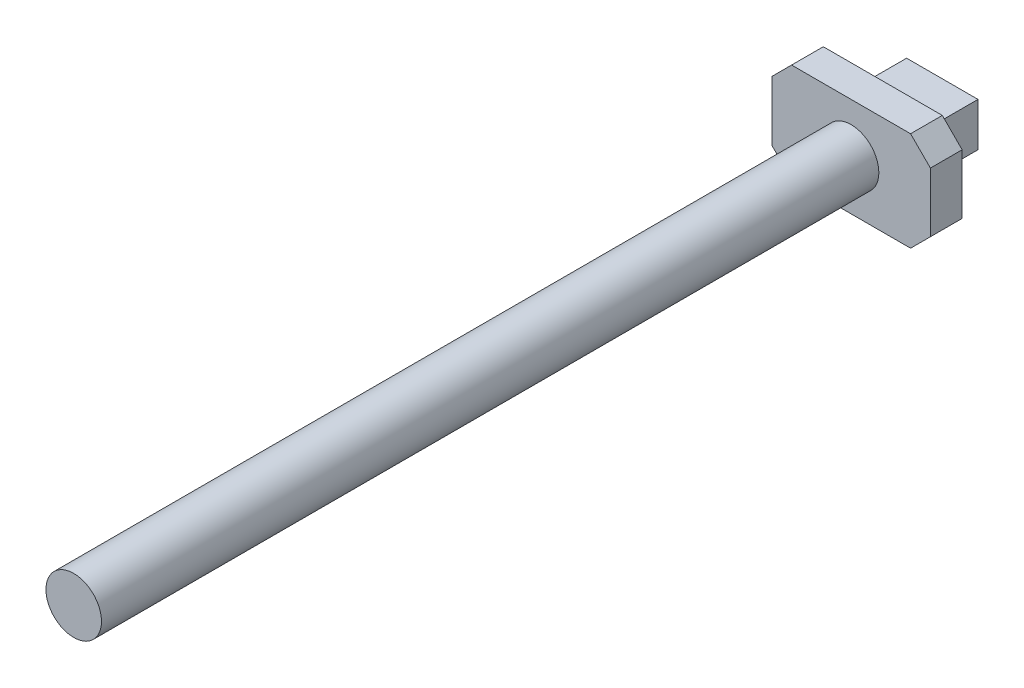
from build123d import *

# Parameters (mm, degrees)
SKETCH_1_R             = 7
EXTRUDE_1_DEPTH        = 160
EXTRUDE_1_DEPTH_BACK   = 36
SKETCH_2_R             = 7
EXTRUDE_2_DEPTH        = 8
SKETCH_3_W             = 18
SKETCH_3_H             = 11
EXTRUDE_3_DEPTH        = 15
EXTRUDE_4_DEPTH        = 30
SKETCH_5_W             = 60
SKETCH_5_H             = 40
EXTRUDE_5_DEPTH        = 6
SKETCH_6_W             = 60
SKETCH_6_H             = 6
EXTRUDE_6_DEPTH        = 60
SKETCH_7_W             = 29.455878384
SKETCH_7_H             = 4
EXTRUDE_7_DEPTH        = 8
PATTERN_LINEAR_1_COUNT = 2
PATTERN_LINEAR_1_PITCH = 52
SKETCH_8_W             = 118.40385017
SKETCH_8_H             = 95.184754192
CUT_EXTRUDE_1_DEPTH    = 200


with BuildPart() as part:
    # 草图1 → 凸台-拉伸1 (new body, two sides)
    with BuildSketch(Plane.XY) as extrude_1_sk:
        Circle(SKETCH_1_R)
    extrude(amount=EXTRUDE_1_DEPTH)
    extrude(extrude_1_sk.sketch, amount=-EXTRUDE_1_DEPTH_BACK)

    # 草图2 → 凸台-拉伸2 (add)
    with BuildSketch(Plane(origin=(0, 0, -36), x_dir=(-1, 0, 0), z_dir=(0, 0, -1))):
        Polygon((20, 7.5), (15, 12.5), (-15, 12.5), (-20, 7.5), (-20, -7.5), (-15, -12.5), (15, -12.5), (20, -7.5), align=None)
        Circle(SKETCH_2_R, mode=Mode.SUBTRACT)
        Circle(SKETCH_2_R)
    extrude(amount=EXTRUDE_2_DEPTH)

    # 草图3 → 凸台-拉伸3 (add)
    with BuildSketch(Plane(origin=(0, 0, -44), x_dir=(-1, 0, 0), z_dir=(0, 0, -1))):
        Rectangle(SKETCH_3_W, SKETCH_3_H)
    extrude(amount=EXTRUDE_3_DEPTH)

    # 草图4 → 凸台-拉伸4 (add)
    with BuildSketch(Plane(origin=(0, 0, -59), x_dir=(-1, 0, 0), z_dir=(0, 0, -1))):
        with BuildLine():
            Line((-15, -12.5), (-15, 12.5))
            ThreePointArc((-15, 12.5), (-27.5, 0), (-15, -12.5))
        make_face()
        with BuildLine():
            ThreePointArc((-3.77502784, 5.5), (-8.385621722, 10.606601718), (-15, 12.5))
            Line((-15, 12.5), (-15, -12.5))
            ThreePointArc((-15, -12.5), (-8.385621722, -10.606601718), (-3.77502784, -5.5))
            Line((-3.77502784, -5.5), (-9, -5.5))
            Line((-9, -5.5), (-9, 5.5))
            Line((-9, 5.5), (-3.77502784, 5.5))
        make_face()
        with BuildLine():
            ThreePointArc((-2.5, 0), (-2.822928267, 2.822928267), (-3.77502784, 5.5))
            Line((-3.77502784, 5.5), (-9, 5.5))
            Line((-9, 5.5), (-9, -5.5))
            Line((-9, -5.5), (-3.77502784, -5.5))
            ThreePointArc((-3.77502784, -5.5), (-2.822928267, -2.822928267), (-2.5, 0))
        make_face()
        with BuildLine():
            ThreePointArc((3.77502784, -5.5), (2.5, 0), (3.77502784, 5.5))
            Line((3.77502784, 5.5), (-3.77502784, 5.5))
            ThreePointArc((-3.77502784, 5.5), (-2.822928267, 2.822928267), (-2.5, 0))
            ThreePointArc((-2.5, 0), (-2.822928267, -2.822928267), (-3.77502784, -5.5))
            Line((-3.77502784, -5.5), (3.77502784, -5.5))
        make_face()
        with BuildLine():
            Line((9, 5.5), (3.77502784, 5.5))
            ThreePointArc((3.77502784, 5.5), (2.5, 0), (3.77502784, -5.5))
            Line((3.77502784, -5.5), (9, -5.5))
            Line((9, -5.5), (9, 5.5))
        make_face()
        with BuildLine():
            Line((15, -12.5), (15, 12.5))
            ThreePointArc((15, 12.5), (8.385621722, 10.606601718), (3.77502784, 5.5))
            Line((3.77502784, 5.5), (9, 5.5))
            Line((9, 5.5), (9, -5.5))
            Line((9, -5.5), (3.77502784, -5.5))
            ThreePointArc((3.77502784, -5.5), (8.385621722, -10.606601718), (15, -12.5))
        make_face()
        with BuildLine():
            ThreePointArc((27.5, 0), (23.838834765, 8.838834765), (15, 12.5))
            Line((15, 12.5), (15, -12.5))
            ThreePointArc((15, -12.5), (23.838834765, -8.838834765), (27.5, 0))
        make_face()
        with BuildLine():
            Line((-15, -12.5), (15, -12.5))
            ThreePointArc((15, -12.5), (8.385621722, -10.606601718), (3.77502784, -5.5))
            Line((3.77502784, -5.5), (-3.77502784, -5.5))
            ThreePointArc((-3.77502784, -5.5), (-8.385621722, -10.606601718), (-15, -12.5))
        make_face()
        with BuildLine():
            ThreePointArc((3.77502784, 5.5), (8.385621722, 10.606601718), (15, 12.5))
            Line((15, 12.5), (-15, 12.5))
            ThreePointArc((-15, 12.5), (-8.385621722, 10.606601718), (-3.77502784, 5.5))
            Line((-3.77502784, 5.5), (3.77502784, 5.5))
        make_face()
    extrude(amount=EXTRUDE_4_DEPTH)

    # 草图5 → 凸台-拉伸5 (add)
    with BuildSketch(Plane(origin=(0, 0, -89), x_dir=(-1, 0, 0), z_dir=(0, 0, -1))):
        Rectangle(SKETCH_5_W, SKETCH_5_H)
    extrude(amount=EXTRUDE_5_DEPTH)

    # 草图6 → 凸台-拉伸6 (add)
    with BuildSketch(Plane(origin=(0, 0, -95), x_dir=(-1, 0, 0), z_dir=(0, 0, -1))):
        with Locations((0, 17)):
            Rectangle(SKETCH_6_W, SKETCH_6_H)
        with Locations((0, -17)):
            Rectangle(SKETCH_6_W, SKETCH_6_H)
    extrude(amount=EXTRUDE_6_DEPTH)

    # 草图7 → 凸台-拉伸7 (add)
    with BuildSketch(Plane.ZY.offset(30)):
        Polygon((-125, 8), (-125, 14), (-155, 14), (-160, 14), (-160, 8), align=None)
        Polygon((-125, -8), (-160, -8), (-160, -14), (-155, -14), (-125, -14), align=None)
        Polygon((-160, 8), (-160, 14), (-166, 14), (-166, 4), (-166, 0), (-166, -4), (-166, -14), (-160, -14), (-160, -8), align=None)
        with Locations((-180.727939192, -2)):
            Rectangle(SKETCH_7_W, SKETCH_7_H)
        with Locations((-180.727939192, 2)):
            Rectangle(SKETCH_7_W, SKETCH_7_H)
    extrude_7 = extrude(amount=-EXTRUDE_7_DEPTH)

    # 阵列(线性)1: 凸台-拉伸7 ×2
    with Locations(*[(i * PATTERN_LINEAR_1_PITCH, 0, 0) for i in range(1, PATTERN_LINEAR_1_COUNT)]):
        add(extrude_7)

    # 草图8 → 切除-拉伸1 (cut)
    with BuildSketch(Plane.XY.offset(-59)):
        Rectangle(SKETCH_8_W, SKETCH_8_H)
    extrude(amount=-CUT_EXTRUDE_1_DEPTH, mode=Mode.SUBTRACT)


solid = part.part
